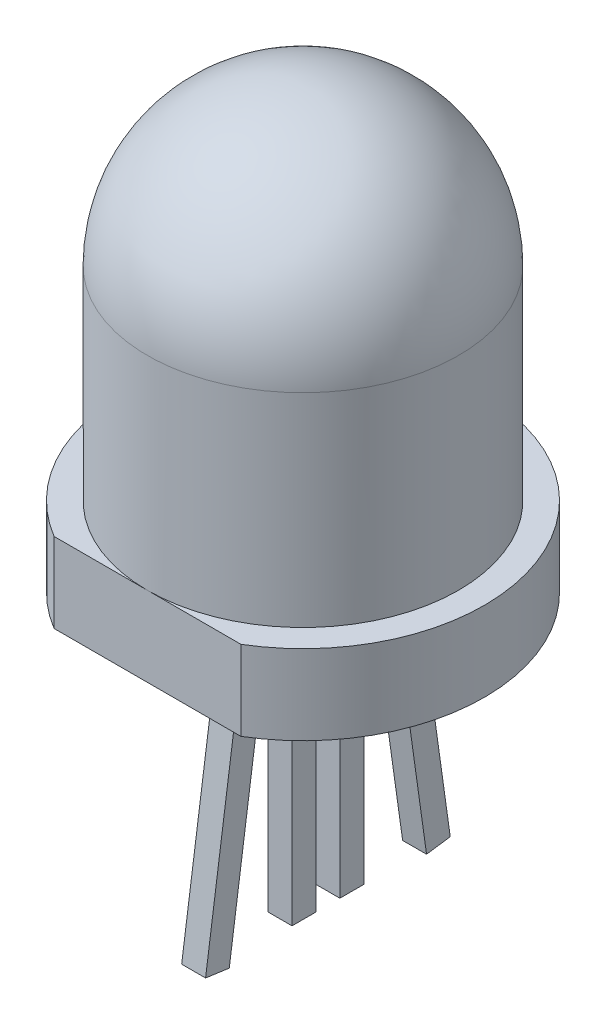
from build123d import *

# Parameters (mm, degrees)
ESQUISSE1_R        = 3.9
BOSS_EXTRU_1_DEPTH = 9
CONG_1_R           = 3.9
BOSS_EXTRU_2_DEPTH = 2
ESQUISSE3_W        = 0.6
ESQUISSE3_H        = 0.6
BOSS_EXTRU_3_DEPTH = 6.8
ESQUISSE6_W        = 0.6
ESQUISSE6_H        = 0.6
BOSS_EXTRU_4_DEPTH = 7
ESQUISSE8_W        = 0.6
ESQUISSE8_H        = 0.6
BOSS_EXTRU_5_DEPTH = 7


with BuildPart() as part:
    # Esquisse1 → Boss.-Extru.1 (new body)
    with BuildSketch(Plane(origin=(0, 0, 0), x_dir=(1, 0, 0), z_dir=(0, 1, 0))):
        Circle(ESQUISSE1_R)
    extrude(amount=BOSS_EXTRU_1_DEPTH)

    # Congé1
    cong_1_edges = [part.edges().sort_by_distance(p)[0] for p in [
        (-3.9, 9, 0),
    ]]
    fillet(cong_1_edges, radius=CONG_1_R)

    # Esquisse2 → Boss.-Extru.2 (add)
    with BuildSketch(Plane.XZ):
        with BuildLine():
            Line((2.343608329, 3.9), (-2.343608329, 3.9))
            ThreePointArc((-2.343608329, 3.9), (0, -4.55), (2.343608329, 3.9))
        make_face()
    extrude(amount=BOSS_EXTRU_2_DEPTH)

    # Esquisse3 → Boss.-Extru.3 (add)
    with BuildSketch(Plane.XZ.offset(2)):
        with Locations((0, 0.275)):
            Rectangle(ESQUISSE3_W, ESQUISSE3_H)
        with Locations((0, -0.925)):
            Rectangle(ESQUISSE3_W, ESQUISSE3_H)
    extrude(amount=BOSS_EXTRU_3_DEPTH)

    # Esquisse6 → Boss.-Extru.4 (add)
    with BuildSketch(Plane(origin=(0, -2.123198642, 0.298396109), x_dir=(-1, 0, 0), z_dir=(0, -0.990268069, 0.139173101))):
        with Locations((0, -1.185218779)):
            Rectangle(ESQUISSE6_W, ESQUISSE6_H)
    extrude(amount=BOSS_EXTRU_4_DEPTH)

    # Esquisse8 → Boss.-Extru.5 (add)
    with BuildSketch(Plane(origin=(0, -2.212780783, -0.310986058), x_dir=(-1, 0, 0), z_dir=(0, -0.990268069, -0.139173101))):
        with Locations((0, 1.828893024)):
            Rectangle(ESQUISSE8_W, ESQUISSE8_H)
    extrude(amount=BOSS_EXTRU_5_DEPTH)


solid = part.part
